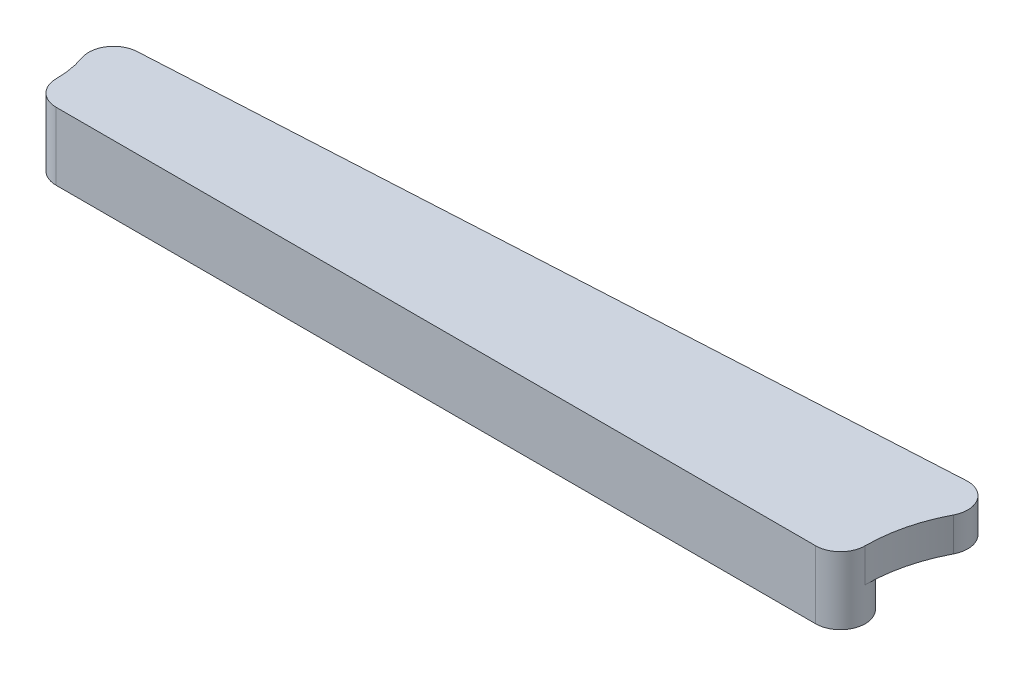
from build123d import *

# Parameters (mm, degrees)
BOSS_EXTRUDE1_DEPTH = 6.499999954
BOSS_EXTRUDE2_DEPTH = 6.5


with BuildPart() as part:
    # Sketch1 → Boss-Extrude1 (new body, symmetric)
    with BuildSketch(Plane(origin=(0, 0, 0), x_dir=(1, 0, 0), z_dir=(0, 1, 0))):
        with BuildLine():
            Line((-73.025, 4.7625), (73.025, 4.7625))
            ThreePointArc((73.025, 4.7625), (77.7875, 0), (73.025, -4.7625))
            Line((73.025, -4.7625), (-73.025, -4.7625))
            ThreePointArc((-73.025, -4.7625), (-77.7875, 0), (-73.025, 4.7625))
        make_face()
    extrude(amount=BOSS_EXTRUDE1_DEPTH, both=True)

    # Sketch3 → Boss-Extrude2 (add)
    with BuildSketch(Plane(origin=(0, 0, 0), x_dir=(1, 0, 0), z_dir=(0, 1, 0))):
        with BuildLine():
            Line((76.658892628, 20.587985299), (-74.559016538, 12.30586185))
            ThreePointArc((-74.559016538, 12.30586185), (-78.253429498, 10.203877505), (-78.797570633, 5.988318736))
            ThreePointArc((-78.797570633, 5.988318736), (-78.041788633, 3.036453687), (-77.7875, 0))
            ThreePointArc((-77.7875, 0), (-76.392596045, 3.367596045), (-73.025, 4.7625))
            Line((-73.025, 4.7625), (73.025, 4.7625))
            ThreePointArc((73.025, 4.7625), (76.392596045, 3.367596045), (77.7875, 0))
            ThreePointArc((77.7875, 0), (78.637537914, 7.014737168), (81.13844531, 13.623410575))
            ThreePointArc((81.13844531, 13.623410575), (80.924845702, 18.408916837), (76.658892628, 20.587985299))
        make_face()
    extrude(amount=BOSS_EXTRUDE2_DEPTH)


solid = part.part
